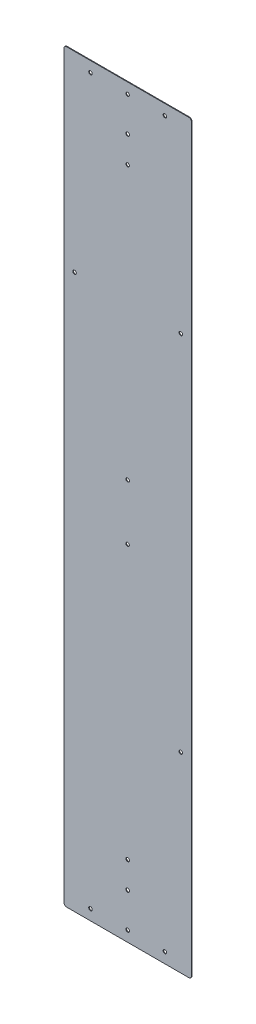
from build123d import *

# Parameters (mm, degrees)
SKETCH1_W                    = 304.8
SKETCH1_H                    = 1781.175
BOSS_EXTRUDE1_DEPTH          = 1.5875
F_5_16_CLEARANCE_HOLE1_D     = 8.4328
F_5_16_CLEARANCE_HOLE1_DEPTH = 1.5875
FILLET4_R                    = 6.35


with BuildPart() as part:
    # Sketch1 → Boss-Extrude1 (new body)
    with BuildSketch(Plane.XY):
        Rectangle(SKETCH1_W, SKETCH1_H)
    extrude(amount=BOSS_EXTRUDE1_DEPTH)

    # 5/16 Clearance Hole1
    with Locations(Plane.XY.offset(1.5875)):
        with Locations((0, 865.1875), (-127, 433.3875), (127, 433.3875), (0, 66.675), (0, -66.675), (127, -433.3875), (0, -865.1875), (0, 782.6375), (0, 719.1375), (0, -782.6375), (0, -719.1375), (-88.9, 865.1875), (88.9, 865.1875), (-88.9, -865.1875), (88.9, -865.1875)):
            Hole(F_5_16_CLEARANCE_HOLE1_D / 2, depth=F_5_16_CLEARANCE_HOLE1_DEPTH)

    # Fillet4
    fillet4_edges = [part.edges().sort_by_distance(p)[0] for p in [
        (152.4, -890.5875, 0.79375),
        (-152.4, -890.5875, 0.79375),
        (-152.4, 890.5875, 0.79375),
        (152.4, 890.5875, 0.79375),
    ]]
    fillet(fillet4_edges, radius=FILLET4_R)


solid = part.part
